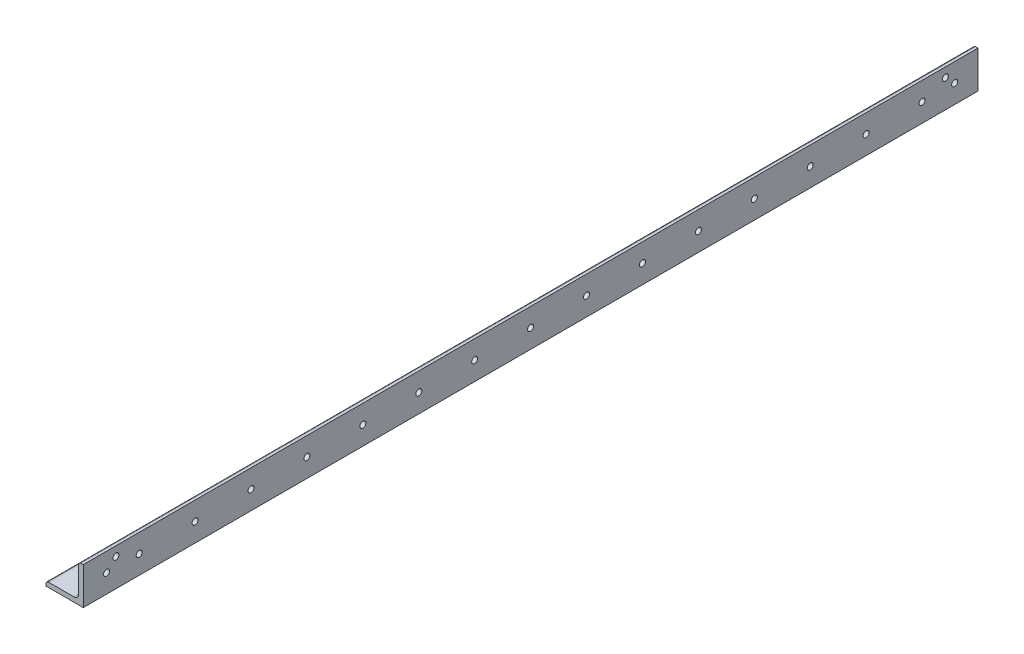
from build123d import *

# Parameters (mm, degrees)
BOSS_EXTRUDE1_DEPTH = 304.8
SKETCH11_R          = 2.05
CUT_EXTRUDE1_DEPTH  = 50.8


with BuildPart() as part:
    # Sketch2 → Boss-Extrude1 (new, symmetric)
    with BuildSketch(Plane.XY):
        with BuildLine():
            Line((-12.7, -12.7), (12.7, -12.7))
            Line((12.7, -12.7), (12.7, 12.7))
            Line((12.7, 12.7), (11.1125, 12.7))
            ThreePointArc((11.1125, 12.7), (9.989967985, 12.235032015), (9.525, 11.1125))
            Line((9.525, 11.1125), (9.525, -6.35))
            ThreePointArc((9.525, -6.35), (8.59506403, -8.59506403), (6.35, -9.525))
            Line((6.35, -9.525), (-11.1125, -9.525))
            ThreePointArc((-11.1125, -9.525), (-12.235032015, -9.989967985), (-12.7, -11.1125))
            Line((-12.7, -11.1125), (-12.7, -12.7))
        make_face()
    extrude(amount=BOSS_EXTRUDE1_DEPTH, both=True)

    # Sketch11 → Cut-Extrude1 (cut)
    with BuildSketch(Plane(origin=(12.7, 0, 0), x_dir=(0, 0, -1), z_dir=(1, 0, 0))):
        with Locations(Location((288.925, 0, 0), (0, 0, 90))):
            Circle(SKETCH11_R)
        with Locations(Location((282.575, 6.35, 0), (0, 0, 90))):
            Circle(SKETCH11_R)
        with Locations(Location((266.7, 0, 0), (0, 0, 90))):
            Circle(SKETCH11_R)
        with Locations(Location((228.6, 0, 0), (0, 0, 90))):
            Circle(SKETCH11_R)
        with Locations(Location((190.5, 0, 0), (0, 0, 90))):
            Circle(SKETCH11_R)
        with Locations(Location((152.4, 0, 0), (0, 0, 90))):
            Circle(SKETCH11_R)
        with Locations(Location((114.3, 0, 0), (0, 0, 90))):
            Circle(SKETCH11_R)
        with Locations(Location((76.2, 0, 0), (0, 0, 90))):
            Circle(SKETCH11_R)
        with Locations(Location((38.1, 0, 0), (0, 0, 90))):
            Circle(SKETCH11_R)
        with Locations(Location((0, 0, 0), (0, 0, 90))):
            Circle(SKETCH11_R)
        with Locations(Location((-38.1, 0, 0), (0, 0, 90))):
            Circle(SKETCH11_R)
        with Locations(Location((-76.2, 0, 0), (0, 0, 90))):
            Circle(SKETCH11_R)
        with Locations(Location((-114.3, 0, 0), (0, 0, 90))):
            Circle(SKETCH11_R)
        with Locations(Location((-152.4, 0, 0), (0, 0, 90))):
            Circle(SKETCH11_R)
        with Locations(Location((-190.5, 0, 0), (0, 0, 90))):
            Circle(SKETCH11_R)
        with Locations(Location((-228.6, 0, 0), (0, 0, 90))):
            Circle(SKETCH11_R)
        with Locations(Location((-266.7, 0, 0), (0, 0, 90))):
            Circle(SKETCH11_R)
        with Locations(Location((-282.575, 6.35, 0), (0, 0, 90))):
            Circle(SKETCH11_R)
        with Locations(Location((-288.925, 0, 0), (0, 0, 90))):
            Circle(SKETCH11_R)
    extrude(amount=-CUT_EXTRUDE1_DEPTH, mode=Mode.SUBTRACT)


solid = part.part
